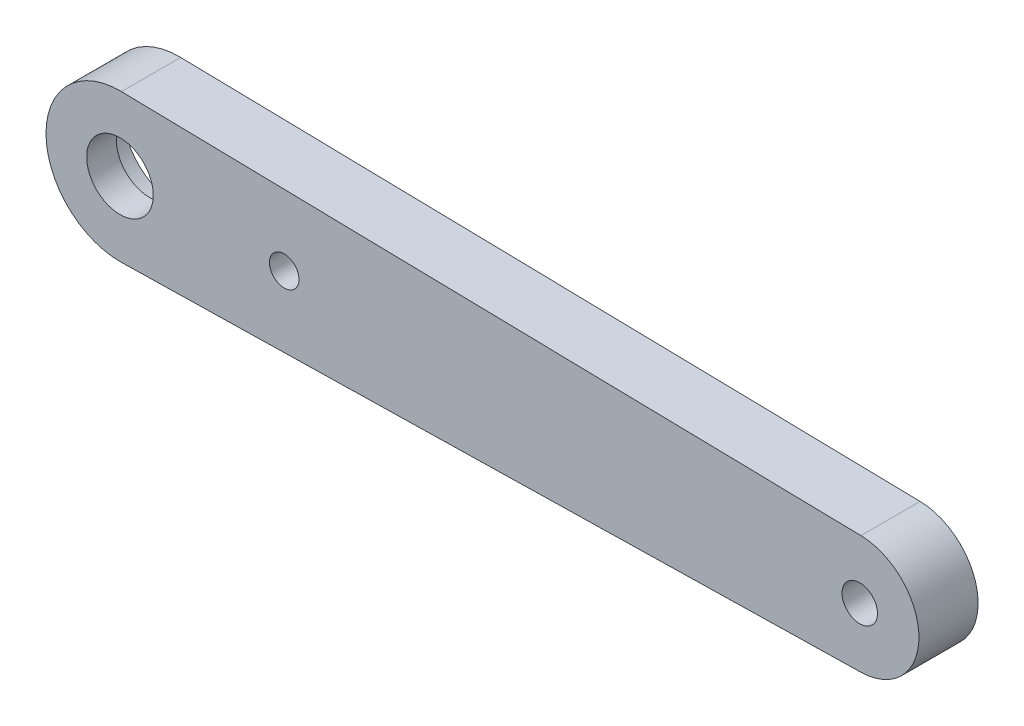
from build123d import *
from build123d.topology import SkipClean

# Parameters (mm, degrees)
SKETCH14_R          = 4
SKETCH14_R_2        = 1.2
SKETCH14_R_3        = 5
BOSS_EXTRUDE1_DEPTH = 4
CUT_EXTRUDE1_START  = -2.5
SKETCH15_R          = 1.2
CUT_EXTRUDE1_DEPTH  = 1.5
CUT_EXTRUDE2_DEPTH  = 0.5
SKETCH17_R          = 1
CUT_EXTRUDE3_DEPTH  = 6
SKETCH18_R          = 2.25
CUT_EXTRUDE4_DEPTH  = 10


with BuildPart() as part:
    # Sketch14 → Boss-Extrude1 (new body)
    with BuildSketch(Plane.XY):
        with BuildLine():
            Line((50.08, 3.99919992), (0.1, 4.9989999))
            ThreePointArc((0.1, 4.9989999), (3.570714214, 3.5), (5, 0))
            ThreePointArc((5, 0), (3.570714214, -3.5), (0.1, -4.9989999))
            Line((0.1, -4.9989999), (50.08, -3.99919992))
            ThreePointArc((50.08, -3.99919992), (46, 0), (50.08, 3.99919992))
        make_face()
        with Locations((50, 0)):
            Circle(SKETCH14_R)
        with Locations((50, 0)):
            Circle(SKETCH14_R_2, mode=Mode.SUBTRACT)
        Circle(SKETCH14_R_3)
        Circle(SKETCH14_R_2, mode=Mode.SUBTRACT)
    extrude(amount=BOSS_EXTRUDE1_DEPTH)

    # Sketch15 → Cut-Extrude1 (cut)
    with BuildSketch(Plane.XY.offset(4).offset(CUT_EXTRUDE1_START)):
        with BuildLine():
            Line((16.121698113, 2.33951917), (0.363207547, 3.832829278))
            ThreePointArc((0.363207547, 3.832829278), (-3.85, 0), (0.363207547, -3.832829278))
            Line((0.363207547, -3.832829278), (16.121698113, -2.33951917))
            ThreePointArc((16.121698113, -2.33951917), (18.25, 0), (16.121698113, 2.33951917))
        make_face()
        Circle(SKETCH15_R, mode=Mode.SUBTRACT)
    extrude(amount=-CUT_EXTRUDE1_DEPTH, mode=Mode.SUBTRACT)

    # Sketch16 → Cut-Extrude2 (cut)
    with SkipClean():  # the faces are left unmerged after this step: merging them gives an invalid solid
        with BuildSketch(Plane(origin=(0, 0, 1.5), x_dir=(-1, 0, 0), z_dir=(0, 0, -1))):
            with BuildLine():
                ThreePointArc((-0.363207547, -3.832829278), (-3.85, 0), (-0.363207547, 3.832829278))
                Line((-0.363207547, 3.832829278), (-6, 3.298674112))
                Line((-6, 3.298674112), (-6, -3.298674112))
                Line((-6, -3.298674112), (-0.363207547, -3.832829278))
            make_face()
            with BuildLine():
                ThreePointArc((3.85, 0), (2.722361108, 2.722361108), (0, 3.85))
                Line((0, 3.85), (0, 1.2))
                ThreePointArc((0, 1.2), (0.848528137, 0.848528137), (1.2, 0))
                ThreePointArc((1.2, 0), (0.848528137, -0.848528137), (0, -1.2))
                Line((0, -1.2), (0, -3.85))
                ThreePointArc((0, -3.85), (2.722361108, -2.722361108), (3.85, 0))
            make_face()
            with BuildLine():
                Line((0, 1.2), (0, 3.85))
                ThreePointArc((0, 3.85), (-0.181806598, 3.845704924), (-0.363207547, 3.832829278))
                ThreePointArc((-0.363207547, 3.832829278), (-3.85, 0), (-0.363207547, -3.832829278))
                ThreePointArc((-0.363207547, -3.832829278), (-0.181806598, -3.845704924), (0, -3.85))
                Line((0, -3.85), (0, -1.2))
                ThreePointArc((0, -1.2), (-1.2, 0), (0, 1.2))
            make_face()
        extrude(amount=-CUT_EXTRUDE2_DEPTH, mode=Mode.SUBTRACT)

    # Sketch17 → Cut-Extrude3 (cut)
    with SkipClean():  # the faces are left unmerged after this step: merging them gives an invalid solid
        with BuildSketch(Plane(origin=(0, 0, 1.5), x_dir=(-1, 0, 0), z_dir=(0, 0, -1))):
            with Locations((-11.1, 0)):
                Circle(SKETCH17_R)
        extrude(amount=-CUT_EXTRUDE3_DEPTH, mode=Mode.SUBTRACT)

    # Sketch18 → Cut-Extrude4 (cut)
    with SkipClean():  # the faces are left unmerged after this step: merging them gives an invalid solid
        with BuildSketch(Plane.XY.offset(4)):
            Circle(SKETCH18_R)
        extrude(amount=-CUT_EXTRUDE4_DEPTH, mode=Mode.SUBTRACT)


solid = part.part
